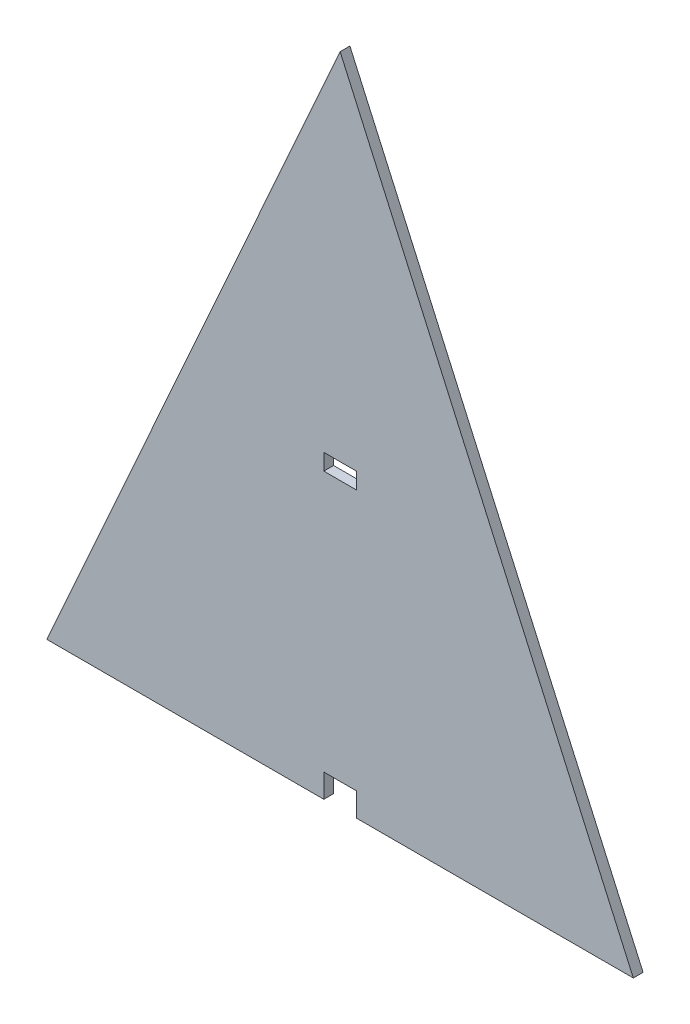
from build123d import *

# Parameters (mm, degrees)
SKETCH1_W           = 10
SKETCH1_H           = 5
BOSS_EXTRUDE1_DEPTH = 3


with BuildPart() as part:
    # Sketch1 → Boss-Extrude1 (new body)
    with BuildSketch(Plane.XY):
        Polygon((90, 201.25), (0, 0), (85, 0), (85, 7.26), (95, 7.26), (95, 0), (180, 0), align=None)
        with Locations((90, 89.737444444)):
            Rectangle(SKETCH1_W, SKETCH1_H, mode=Mode.SUBTRACT)
    extrude(amount=BOSS_EXTRUDE1_DEPTH)


solid = part.part
